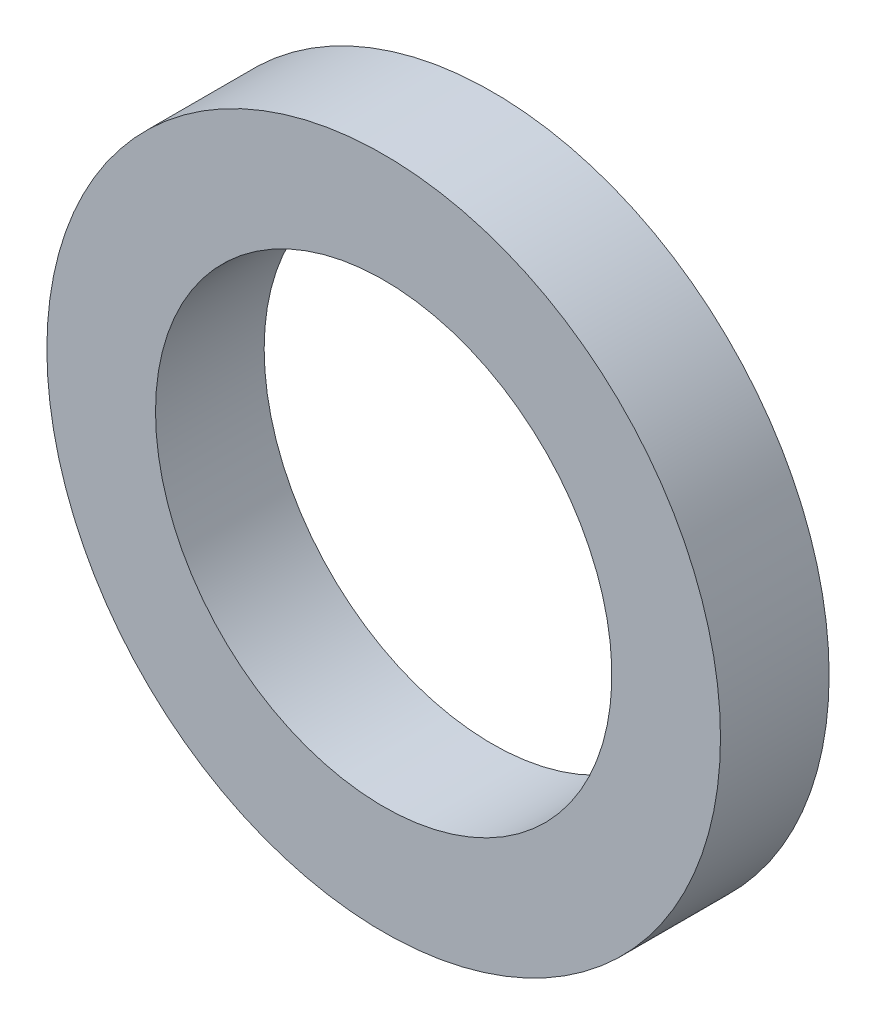
from build123d import *

# Parameters (mm, degrees)
SKETCH1_R           = 3.1
BOSS_EXTRUDE3_DEPTH = 1
SKETCH3_R           = 2.1
CUT_EXTRUDE1_DEPTH  = 2


with BuildPart() as part:
    # Sketch1 → Boss-Extrude3 (new body)
    with BuildSketch(Plane.XY):
        Circle(SKETCH1_R)
    extrude(amount=BOSS_EXTRUDE3_DEPTH)

    # Sketch3 → Cut-Extrude1 (cut, through all)
    with BuildSketch(Plane(origin=(0, 0, 0), x_dir=(-1, 0, 0), z_dir=(0, 0, -1))):
        Circle(SKETCH3_R)
    extrude(amount=-CUT_EXTRUDE1_DEPTH, mode=Mode.SUBTRACT)


solid = part.part
